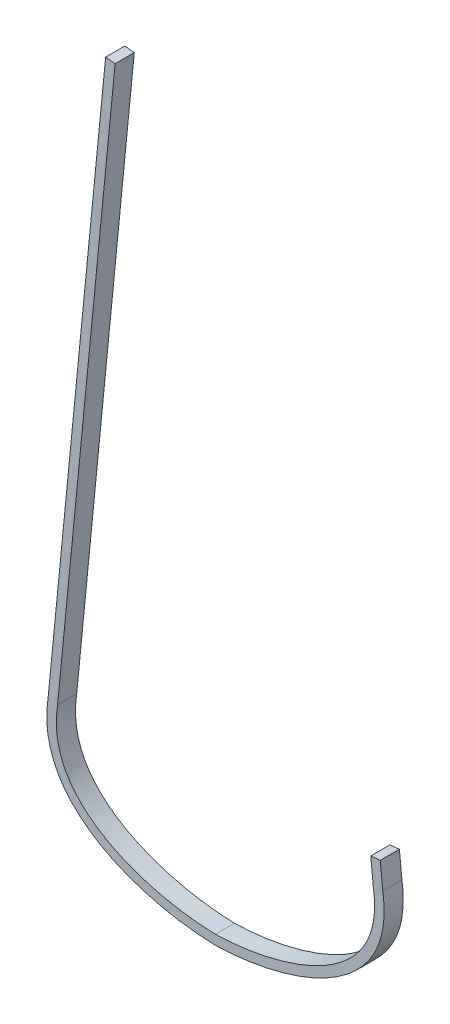
from build123d import *

# Parameters (mm, degrees)
BOSS_EXTRUDE1_DEPTH = 19.05


with BuildPart() as part:
    # Sketch1 → Boss-Extrude1 (new body)
    with BuildSketch(Plane.XY):
        with BuildLine():
            Line((157.234081882, 128.980548454), (154.716315658, 154.51789158))
            Line((154.716315658, 154.51789158), (164.195357535, 155.452445004))
            Line((164.195357535, 155.452445004), (166.6875, 130.175))
            add(Edge.make_bspline(
                [(0, 0), (73.666580622, 1.740675992), (181.188092361, 36.200835609), (166.6875, 130.175)],
                knots=[0, 0, 0, 0, 1, 1, 1, 1], degree=3))
            add(Edge.make_bspline(
                [(0, 0), (-73.666580622, 1.740675992), (-181.188092361, 36.200835609), (-166.6875, 130.175)],
                knots=[0, 0, 0, 0, 1, 1, 1, 1], degree=3))
            Line((-166.6875, 130.175), (-109.368223301, 711.556235093))
            Line((-109.368223301, 711.556235093), (-99.889181424, 710.621681669))
            Line((-99.889181424, 710.621681669), (-157.234081882, 128.980548454))
            add(Edge.make_bspline(
                [(0, 9.52776174), (-1.117611602, 9.555193192), (-3.340472897, 9.624755056), (-7.880039481, 9.827207732), (-13.652210416, 10.198958437), (-20.725459036, 10.840441372), (-30.303235723, 11.962316267), (-42.47749757, 13.875858033), (-57.165232888, 17.02314898), (-71.689613059, 21.050850851), (-90.515854195, 27.626537064), (-112.436111514, 38.157452487), (-130.643933928, 51.803557723), (-142.189146149, 64.564536934), (-149.192253507, 75.075537554), (-153.541361304, 84.674022673), (-156.058613173, 92.923629982), (-157.442658539, 99.418206789), (-158.29640922, 106.242287005), (-158.540175044, 112.221426054), (-158.437150466, 117.190167219), (-158.20642164, 121.010360535), (-157.881730698, 124.277278241), (-157.584058118, 126.601085874), (-157.415798733, 127.781927866), (-157.316566229, 128.446705395), (-157.261207353, 128.804756083), (-157.234081882, 128.980548454)],
                knots=[0.001057036, 0.001057036, 0.001057036, 0.001057036, 0.016679825, 0.032302613, 0.063548191, 0.094793768, 0.126039346, 0.1885305, 0.251021655, 0.31351281, 0.376003965, 0.500986274, 0.625968584, 0.688459739, 0.750950893, 0.813442048, 0.844687626, 0.875933203, 0.90717878, 0.938424358, 0.954047147, 0.969669935, 0.985292724, 0.993104118, 0.997009815, 0.998962664, 1.000915513, 1.000915513, 1.000915513, 1.000915513], degree=3))
            add(Edge.make_bspline(
                [(157.234081882, 128.980548454), (157.261207353, 128.804756083), (157.316566229, 128.446705395), (157.415798733, 127.781927866), (157.584058118, 126.601085874), (157.881730698, 124.277278241), (158.20642164, 121.010360535), (158.437150466, 117.190167219), (158.540175044, 112.221426054), (158.29640922, 106.242287005), (157.442658539, 99.418206789), (156.058613173, 92.923629982), (153.541361304, 84.674022673), (149.192253507, 75.075537554), (142.189146149, 64.564536934), (130.643933928, 51.803557723), (112.436111514, 38.157452487), (90.515854195, 27.626537064), (71.689613059, 21.050850851), (57.165232888, 17.02314898), (42.47749757, 13.875858033), (30.303235723, 11.962316267), (20.725459036, 10.840441372), (13.652210416, 10.198958437), (7.880039481, 9.827207732), (3.340472897, 9.624755056), (1.117611602, 9.555193192), (0, 9.52776174)],
                knots=[0.001057036, 0.001057036, 0.001057036, 0.001057036, 0.003009885, 0.004962733, 0.00886843, 0.016679825, 0.032302613, 0.047925402, 0.063548191, 0.094793768, 0.126039346, 0.157284923, 0.1885305, 0.251021655, 0.31351281, 0.376003965, 0.500986274, 0.625968584, 0.688459739, 0.750950893, 0.813442048, 0.875933203, 0.90717878, 0.938424358, 0.969669935, 0.985292724, 1.000915513, 1.000915513, 1.000915513, 1.000915513], degree=3))
        make_face()
    extrude(amount=BOSS_EXTRUDE1_DEPTH)


solid = part.part
